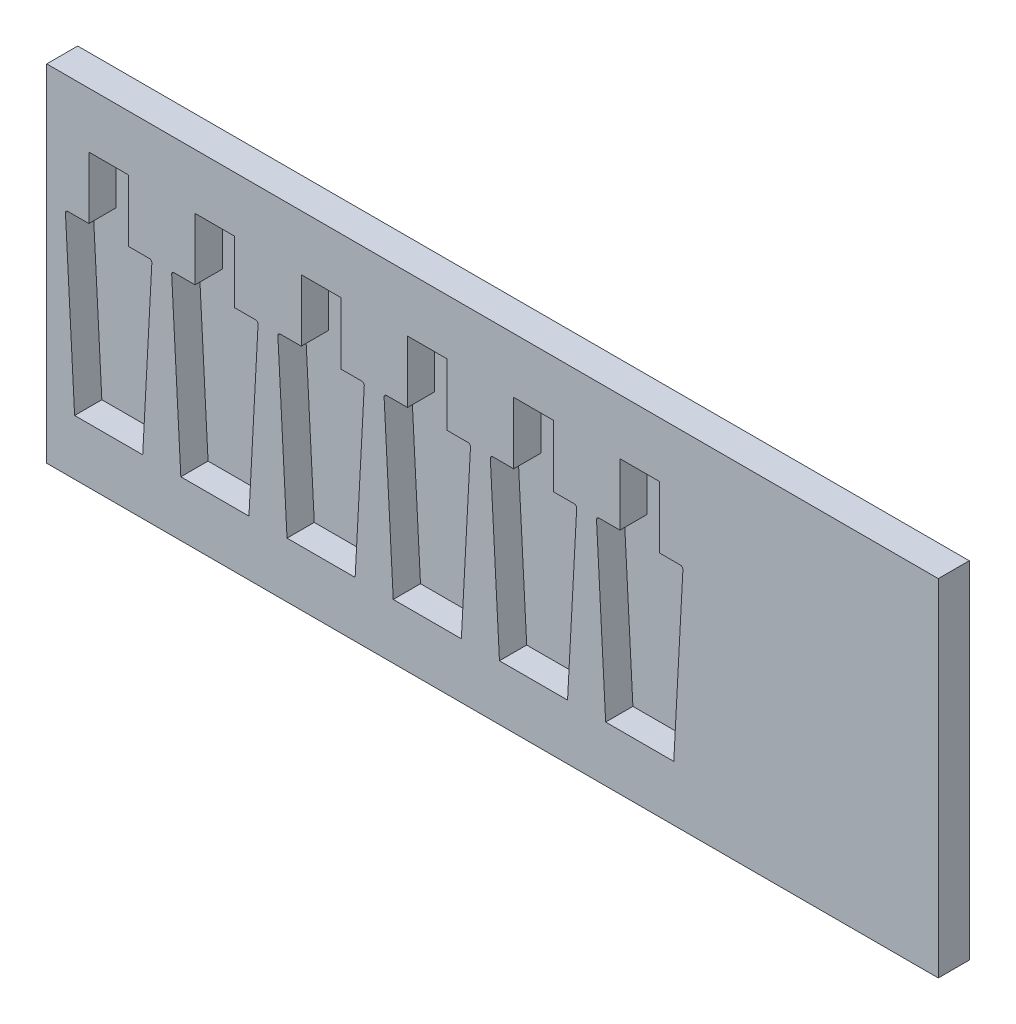
from build123d import *

# Parameters (mm, degrees)
SKETCH2_W           = 720
SKETCH2_H           = 279.33
BOSS_EXTRUDE1_DEPTH = 25
CUT_EXTRUDE1_DEPTH  = 22


with BuildPart() as part:
    # Sketch2 → Boss-Extrude1 (new body)
    with BuildSketch(Plane.XY):
        Rectangle(SKETCH2_W, SKETCH2_H)
    extrude(amount=BOSS_EXTRUDE1_DEPTH)

    # Sketch4 → Cut-Extrude1 (cut)
    with BuildSketch(Plane.XY.offset(25)):
        with BuildLine():
            Line((-326, 45), (-342.889989301, 45))
            ThreePointArc((-342.889989301, 45), (-344.341536559, 44.375867202), (-344.887125566, 42.893010557))
            Line((-344.887125566, 42.893010557), (-337.5, -95))
            Line((-337.5, -95), (-282.5, -95))
            Line((-282.5, -95), (-275.112874434, 42.893010557))
            ThreePointArc((-275.112874434, 42.893010557), (-275.658463441, 44.375867202), (-277.110010699, 45))
            Line((-277.110010699, 45), (-294, 45))
            Line((-294, 45), (-294, 95))
            Line((-294, 95), (-326, 95))
            Line((-326, 95), (-326, 45))
        make_face()
        with BuildLine():
            Line((-110.951497738, -95), (-103.564372172, 42.893010557))
            ThreePointArc((-103.564372172, 42.893010557), (-104.109961179, 44.375867202), (-105.561508437, 45))
            Line((-105.561508437, 45), (-122.451497738, 45))
            Line((-122.451497738, 45), (-122.451497738, 95))
            Line((-122.451497738, 95), (-154.451497738, 95))
            Line((-154.451497738, 95), (-154.451497738, 45))
            Line((-154.451497738, 45), (-171.341487039, 45))
            ThreePointArc((-171.341487039, 45), (-172.793034297, 44.375867202), (-173.338623303, 42.893010557))
            Line((-173.338623303, 42.893010557), (-165.951497738, -95))
            Line((-165.951497738, -95), (-110.951497738, -95))
        make_face()
        with BuildLine():
            Line((-259.112874434, 42.893010557), (-251.725748869, -95))
            Line((-251.725748869, -95), (-196.725748869, -95))
            Line((-196.725748869, -95), (-189.338623303, 42.893010557))
            ThreePointArc((-189.338623303, 42.893010557), (-189.88421231, 44.375867202), (-191.335759568, 45))
            Line((-191.335759568, 45), (-208.225748869, 45))
            Line((-208.225748869, 45), (-208.225748869, 95))
            Line((-208.225748869, 95), (-240.225748869, 95))
            Line((-240.225748869, 95), (-240.225748869, 45))
            Line((-240.225748869, 45), (-257.11573817, 45))
            ThreePointArc((-257.11573817, 45), (-258.567285428, 44.375867202), (-259.112874434, 42.893010557))
        make_face()
        with BuildLine():
            Line((-25.177246607, -95), (-17.790121041, 42.893010557))
            ThreePointArc((-17.790121041, 42.893010557), (-18.335710047, 44.375867202), (-19.787257306, 45))
            Line((-19.787257306, 45), (-36.677246607, 45))
            Line((-36.677246607, 45), (-36.677246607, 95))
            Line((-36.677246607, 95), (-68.677246607, 95))
            Line((-68.677246607, 95), (-68.677246607, 45))
            Line((-68.677246607, 45), (-85.567235908, 45))
            ThreePointArc((-85.567235908, 45), (-87.018783166, 44.375867202), (-87.564372172, 42.893010557))
            Line((-87.564372172, 42.893010557), (-80.177246607, -95))
            Line((-80.177246607, -95), (-25.177246607, -95))
        make_face()
        with BuildLine():
            Line((60.597004525, -95), (67.98413009, 42.893010557))
            ThreePointArc((67.98413009, 42.893010557), (67.438541084, 44.375867202), (65.986993826, 45))
            Line((65.986993826, 45), (49.097004525, 45))
            Line((49.097004525, 45), (49.097004525, 95))
            Line((49.097004525, 95), (17.097004525, 95))
            Line((17.097004525, 95), (17.097004525, 45))
            Line((17.097004525, 45), (0.207015224, 45))
            ThreePointArc((0.207015224, 45), (-1.244532035, 44.375867202), (-1.790121041, 42.893010557))
            Line((-1.790121041, 42.893010557), (5.597004525, -95))
            Line((5.597004525, -95), (60.597004525, -95))
        make_face()
        with BuildLine():
            Line((83.98413009, 42.893010557), (91.371255656, -95))
            Line((91.371255656, -95), (146.371255656, -95))
            Line((146.371255656, -95), (153.758381221, 42.893010557))
            ThreePointArc((153.758381221, 42.893010557), (153.212792215, 44.375867202), (151.761244957, 45))
            Line((151.761244957, 45), (134.871255656, 45))
            Line((134.871255656, 45), (134.871255656, 95))
            Line((134.871255656, 95), (102.871255656, 95))
            Line((102.871255656, 95), (102.871255656, 45))
            Line((102.871255656, 45), (85.981266355, 45))
            ThreePointArc((85.981266355, 45), (84.529719096, 44.375867202), (83.98413009, 42.893010557))
        make_face()
    extrude(amount=-CUT_EXTRUDE1_DEPTH, mode=Mode.SUBTRACT)


solid = part.part
